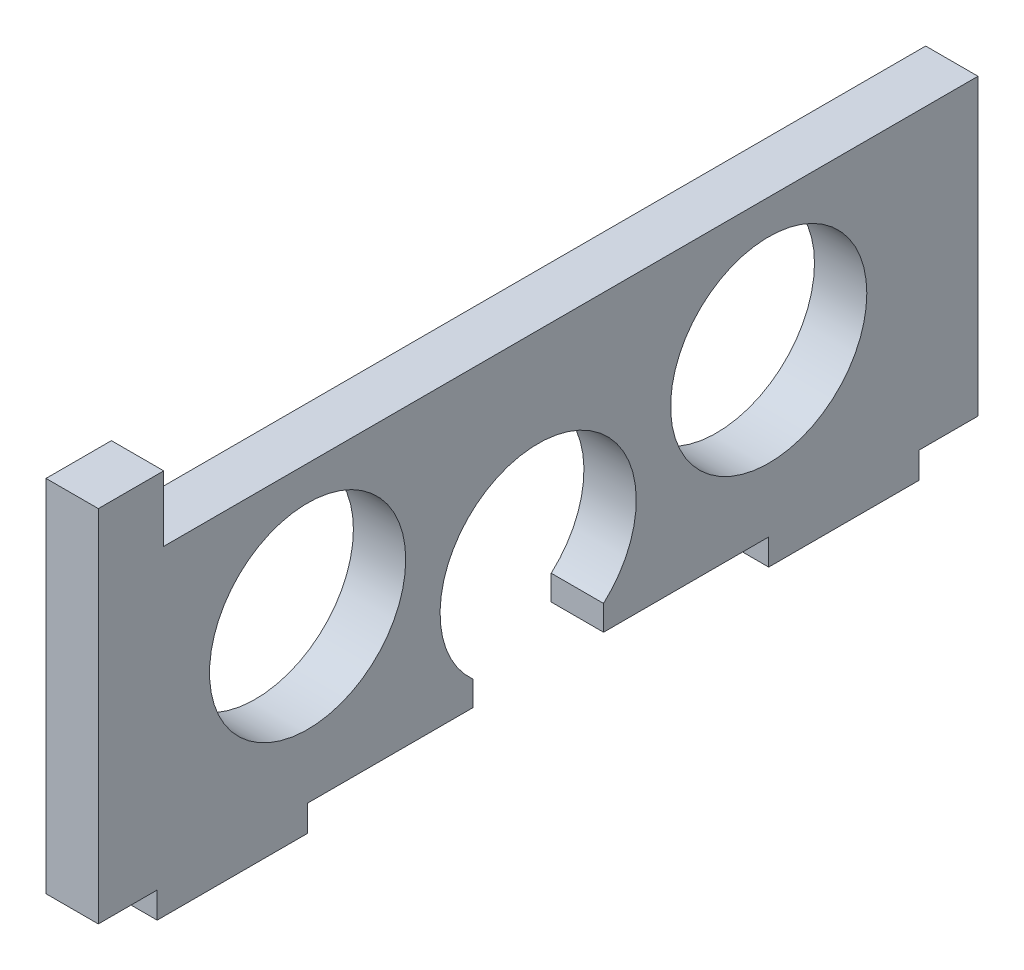
from build123d import *

# Parameters (mm, degrees)
SKETCH_2_R      = 3
EXTRUDE_1_DEPTH = 1.6


with BuildPart() as part:
    # 스케치2 → 보스-돌출1 (new body)
    with BuildSketch(Plane(origin=(0, 0, 0), x_dir=(0, 0, -1), z_dir=(1, 0, 0))):
        with BuildLine():
            Line((-13.45, 1.3), (-11.65, 1.3))
            Line((-11.65, 1.3), (-11.65, 0.5))
            Line((-11.65, 0.5), (-7.05, 0.5))
            Line((-7.05, 0.5), (-7.05, 1.3))
            Line((-7.05, 1.3), (-2, 1.3))
            Line((-2, 1.3), (-2, 2.063932023))
            ThreePointArc((-2, 2.063932023), (0, 7.3), (2, 2.063932023))
            Line((2, 2.063932023), (2, 1.3))
            Line((2, 1.3), (7.05, 1.3))
            Line((7.05, 1.3), (7.05, 0.5))
            Line((7.05, 0.5), (11.65, 0.5))
            Line((11.65, 0.5), (11.65, 1.3))
            Line((11.65, 1.3), (13.45, 1.3))
            Line((13.45, 1.3), (13.45, 10.3))
            Line((13.45, 10.3), (-11.45, 10.3))
            Line((-11.45, 10.3), (-11.45, 12.3))
            Line((-11.45, 12.3), (-13.45, 12.3))
            Line((-13.45, 12.3), (-13.45, 1.3))
        make_face()
        with Locations((-7.05, 6.25)):
            Circle(SKETCH_2_R, mode=Mode.SUBTRACT)
        with Locations((7.05, 6.25)):
            Circle(SKETCH_2_R, mode=Mode.SUBTRACT)
    extrude(amount=EXTRUDE_1_DEPTH)


solid = part.part
